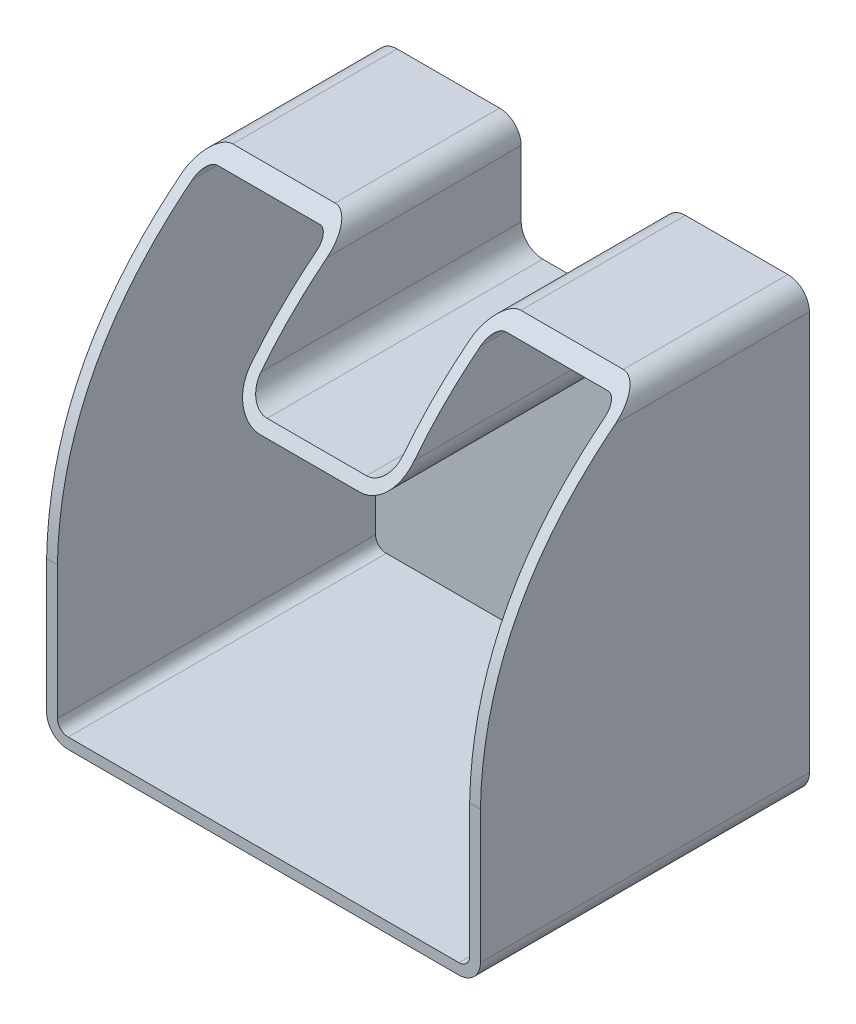
from build123d import *

# Parameters (mm, degrees)
BOSS_EXTRUDE2_DEPTH      = 10
BOSS_EXTRUDE2_DEPTH_BACK = 51
SHELL2_T                 = -2
CUT_EXTRUDE2_DEPTH       = 81.44
SKETCH4_R                = 5.05
CUT_EXTRUDE3_DEPTH       = 62.0000001


with BuildPart() as part:
    # Sketch1 → Boss-Extrude2 (new body, two sides)
    with BuildSketch(Plane(origin=(0, 0, 1146.708434145), x_dir=(-1, 0, 0), z_dir=(0, 0, -1))) as boss_extrude2_sk:
        with BuildLine():
            Line((398.052845122, -24.322837047), (325.612845122, -24.322837047))
            ThreePointArc((325.612845122, -24.322837047), (322.784417997, -23.151264171), (321.612845122, -20.322837047))
            Line((321.612845122, -20.322837047), (321.612845122, 53.677162953))
            ThreePointArc((321.612845122, 53.677162953), (322.784417997, 56.505590078), (325.612845122, 57.677162953))
            Line((325.612845122, 57.677162953), (344.612845122, 57.677162953))
            ThreePointArc((344.612845122, 57.677162953), (347.441272247, 56.505590078), (348.612845122, 53.677162953))
            Line((348.612845122, 53.677162953), (348.612845122, 41.420568524))
            ThreePointArc((348.612845122, 41.420568524), (349.784417997, 38.5921414), (352.612845122, 37.420568524))
            Line((352.612845122, 37.420568524), (371.052845122, 37.420568524))
            ThreePointArc((371.052845122, 37.420568524), (373.881272247, 38.5921414), (375.052845122, 41.420568524))
            Line((375.052845122, 41.420568524), (375.052845122, 53.677162953))
            ThreePointArc((375.052845122, 53.677162953), (376.224417997, 56.505590078), (379.052845122, 57.677162953))
            Line((379.052845122, 57.677162953), (398.052845122, 57.677162953))
            ThreePointArc((398.052845122, 57.677162953), (400.881272247, 56.505590078), (402.052845122, 53.677162953))
            Line((402.052845122, 53.677162953), (402.052845122, -20.322837047))
            ThreePointArc((402.052845122, -20.322837047), (400.881272247, -23.151264171), (398.052845122, -24.322837047))
        make_face()
    extrude(amount=BOSS_EXTRUDE2_DEPTH)
    extrude(boss_extrude2_sk.sketch, amount=-BOSS_EXTRUDE2_DEPTH_BACK)

    # Shell2
    shell2_openings = [part.faces().sort_by_distance(p)[0] for p in [
        (-361.832845122, 32.113014346, 1197.708434145),
    ]]
    offset(amount=SHELL2_T, openings=shell2_openings, kind=Kind.INTERSECTION)

    # Sketch2 → Cut-Extrude2 (cut, through all)
    with BuildSketch(Plane(origin=(-321.612845122, 0, 0), x_dir=(0, 0, -1), z_dir=(1, 0, 0))):
        with BuildLine():
            Line((-1197.708434145, 4.331235789), (-1202.700494478, 4.331235789))
            Line((-1202.700494478, 4.331235789), (-1202.700494478, 60.889226386))
            Line((-1202.700494478, 60.889226386), (-1167.208434145, 60.889226386))
            Line((-1167.208434145, 60.889226386), (-1167.208434145, 57.677162953))
            add(Edge.make_bspline(
                [(-1197.708434145, 4.331235789), (-1197.068834598, 37.525012085), (-1167.208434145, 57.677162953)],
                knots=[0, 0, 0, 1, 1, 1], degree=2))
        make_face()
    extrude(amount=-CUT_EXTRUDE2_DEPTH, mode=Mode.SUBTRACT)

    # Sketch4 → Cut-Extrude3 (cut, through all)
    with BuildSketch(Plane(origin=(0, 0, 1136.708434145), x_dir=(-1, 0, 0), z_dir=(0, 0, -1))):
        with Locations((335.112845122, 47.548865739)):
            Circle(SKETCH4_R)
    extrude(amount=-CUT_EXTRUDE3_DEPTH, mode=Mode.SUBTRACT)


solid = part.part
